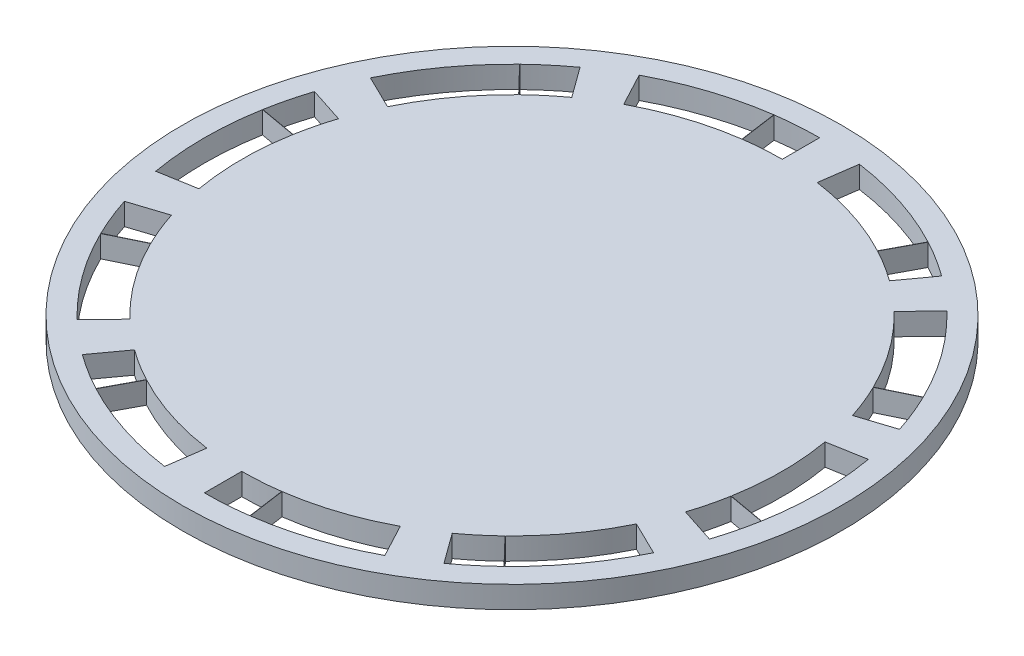
from build123d import *

# Parameters (mm, degrees)
SKETCH1_R           = 38.1
BOSS_EXTRUDE3_DEPTH = 2.54


with BuildPart() as part:
    # Sketch1 → Boss-Extrude3 (new body)
    with BuildSketch(Plane(origin=(0, 0, 0), x_dir=(1, 0, 0), z_dir=(0, 1, 0))):
        with Locations(Location((-25.836673929, 73.693240411, 0), (0, 0, 270))):  # turned: the seam where the file's is
            Circle(SKETCH1_R)
        with BuildLine():
            Line((6.124442357, 89.281718391), (2.243449665, 87.388831779))
            ThreePointArc((2.243449665, 87.388831779), (-0.561364991, 92.056827263), (-4.134157119, 96.166854453))
            Line((-4.134157119, 96.166854453), (-1.134622276, 99.272963711))
            ThreePointArc((-1.134622276, 99.272963711), (2.931970391, 94.594883983), (6.124442357, 89.281718391))
        make_face(mode=Mode.SUBTRACT)
        with BuildLine():
            Line((-4.935030358, 102.461884731), (-7.473087077, 98.968549349))
            ThreePointArc((-7.473087077, 98.968549349), (-9.26937735, 100.180732706), (-11.145376456, 101.265479032))
            Line((-11.145376456, 101.265479032), (-9.114871927, 105.07627624))
            ThreePointArc((-9.114871927, 105.07627624), (-6.979588392, 103.841605625), (-4.935030358, 102.461884731))
        make_face(mode=Mode.SUBTRACT)
        with BuildLine():
            Line((9.183089768, 67.518311213), (4.930689891, 68.268124045))
            ThreePointArc((4.930689891, 68.268124045), (5.405326071, 73.693240411), (4.930689891, 79.118356778))
            Line((4.930689891, 79.118356778), (9.183089768, 79.868169609))
            ThreePointArc((9.183089768, 79.868169609), (9.723326071, 73.693240411), (9.183089768, 67.518311213))
        make_face(mode=Mode.SUBTRACT)
        with BuildLine():
            Line((7.98289579, 84.681884731), (3.876233753, 83.347549349))
            ThreePointArc((3.876233753, 83.347549349), (3.135507895, 85.384059217), (2.25539063, 87.364322037))
            Line((2.25539063, 87.364322037), (6.138033699, 89.253821123))
            ThreePointArc((6.138033699, 89.253821123), (7.139793188, 86.999863442), (7.98289579, 84.681884731))
        make_face(mode=Mode.SUBTRACT)
        with BuildLine():
            Line((-1.134622276, 48.113517111), (-4.134157119, 51.219626369))
            ThreePointArc((-4.134157119, 51.219626369), (-0.561364991, 55.329653559), (2.243449665, 59.997649043))
            Line((2.243449665, 59.997649043), (6.124442357, 58.104762431))
            ThreePointArc((6.124442357, 58.104762431), (2.931970391, 52.79159684), (-1.134622276, 48.113517111))
        make_face(mode=Mode.SUBTRACT)
        with BuildLine():
            Line((7.98289579, 62.704596091), (3.876233753, 64.038931473))
            ThreePointArc((3.876233753, 64.038931473), (4.474004412, 66.1218903), (4.925943869, 68.241276524))
            Line((4.925943869, 68.241276524), (9.177687792, 67.487753059))
            ThreePointArc((9.177687792, 67.487753059), (8.663285158, 65.075443537), (7.98289579, 62.704596091))
        make_face(mode=Mode.SUBTRACT)
        with BuildLine():
            Line((-20.887678459, 38.479307887), (-21.488627909, 42.755285408))
            ThreePointArc((-21.488627909, 42.755285408), (-16.182364991, 43.980332729), (-11.169443364, 46.108191715))
            Line((-11.169443364, 46.108191715), (-9.142265156, 42.295624009))
            ThreePointArc((-9.142265156, 42.295624009), (-14.848029609, 39.873670692), (-20.887678459, 38.479307887))
        make_face(mode=Mode.SUBTRACT)
        with BuildLine():
            Line((-4.935030358, 44.924596091), (-7.473087077, 48.417931473))
            ThreePointArc((-7.473087077, 48.417931473), (-5.765147975, 49.751719785), (-4.153777308, 51.20069591))
            Line((-4.153777308, 51.20069591), (-1.156954198, 48.091970247))
            ThreePointArc((-1.156954198, 48.091970247), (-2.991034632, 46.44272913), (-4.935030358, 44.924596091))
        make_face(mode=Mode.SUBTRACT)
        with BuildLine():
            Line((-42.531082702, 42.295624009), (-40.503904494, 46.108191715))
            ThreePointArc((-40.503904494, 46.108191715), (-35.490982867, 43.980332729), (-30.184719949, 42.755285408))
            Line((-30.184719949, 42.755285408), (-30.785669399, 38.479307887))
            ThreePointArc((-30.785669399, 38.479307887), (-36.825318249, 39.873670692), (-42.531082702, 42.295624009))
        make_face(mode=Mode.SUBTRACT)
        with BuildLine():
            Line((-25.836673929, 38.133240411), (-25.836673929, 42.451240411))
            ThreePointArc((-25.836673929, 42.451240411), (-23.670941071, 42.526396407), (-21.51562802, 42.751502802))
            Line((-21.51562802, 42.751502802), (-20.918410293, 38.475002482))
            ThreePointArc((-20.918410293, 38.475002482), (-23.371612139, 38.218783821), (-25.836673929, 38.133240411))
        make_face(mode=Mode.SUBTRACT)
        with BuildLine():
            Line((-57.797790215, 58.104762431), (-53.916797524, 59.997649043))
            ThreePointArc((-53.916797524, 59.997649043), (-51.111982867, 55.329653559), (-47.539190739, 51.219626369))
            Line((-47.539190739, 51.219626369), (-50.538725583, 48.113517111))
            ThreePointArc((-50.538725583, 48.113517111), (-54.605318249, 52.79159684), (-57.797790215, 58.104762431))
        make_face(mode=Mode.SUBTRACT)
        with BuildLine():
            Line((-46.738317501, 44.924596091), (-44.200260781, 48.417931473))
            ThreePointArc((-44.200260781, 48.417931473), (-42.403970508, 47.205748116), (-40.527971402, 46.12100179))
            Line((-40.527971402, 46.12100179), (-42.558475931, 42.310204583))
            ThreePointArc((-42.558475931, 42.310204583), (-44.693759466, 43.544875197), (-46.738317501, 44.924596091))
        make_face(mode=Mode.SUBTRACT)
        with BuildLine():
            Line((-60.856437626, 79.868169609), (-56.604037749, 79.118356778))
            ThreePointArc((-56.604037749, 79.118356778), (-57.078673929, 73.693240411), (-56.604037749, 68.268124045))
            Line((-56.604037749, 68.268124045), (-60.856437626, 67.518311213))
            ThreePointArc((-60.856437626, 67.518311213), (-61.396673929, 73.693240411), (-60.856437626, 79.868169609))
        make_face(mode=Mode.SUBTRACT)
        with BuildLine():
            Line((-59.656243648, 62.704596091), (-55.549581611, 64.038931473))
            ThreePointArc((-55.549581611, 64.038931473), (-54.808855753, 62.002421606), (-53.928738488, 60.022158786))
            Line((-53.928738488, 60.022158786), (-57.811381557, 58.132659699))
            ThreePointArc((-57.811381557, 58.132659699), (-58.813141046, 60.38661738), (-59.656243648, 62.704596091))
        make_face(mode=Mode.SUBTRACT)
        with BuildLine():
            Line((-50.538725583, 99.272963711), (-47.539190739, 96.166854453))
            ThreePointArc((-47.539190739, 96.166854453), (-51.111982867, 92.056827263), (-53.916797524, 87.388831779))
            Line((-53.916797524, 87.388831779), (-57.797790215, 89.281718391))
            ThreePointArc((-57.797790215, 89.281718391), (-54.605318249, 94.594883983), (-50.538725583, 99.272963711))
        make_face(mode=Mode.SUBTRACT)
        with BuildLine():
            Line((-59.656243648, 84.681884731), (-55.549581611, 83.347549349))
            ThreePointArc((-55.549581611, 83.347549349), (-56.14735227, 81.264590522), (-56.599291727, 79.145204299))
            Line((-56.599291727, 79.145204299), (-60.85103565, 79.898727763))
            ThreePointArc((-60.85103565, 79.898727763), (-60.336633016, 82.311037286), (-59.656243648, 84.681884731))
        make_face(mode=Mode.SUBTRACT)
        with BuildLine():
            Line((-30.785669399, 108.907172936), (-30.184719949, 104.631195415))
            ThreePointArc((-30.184719949, 104.631195415), (-35.490982867, 103.406148093), (-40.503904494, 101.278289107))
            Line((-40.503904494, 101.278289107), (-42.531082702, 105.090856813))
            ThreePointArc((-42.531082702, 105.090856813), (-36.825318249, 107.512810131), (-30.785669399, 108.907172936))
        make_face(mode=Mode.SUBTRACT)
        with BuildLine():
            Line((-46.738317501, 102.461884731), (-44.200260781, 98.968549349))
            ThreePointArc((-44.200260781, 98.968549349), (-45.908199883, 97.634761037), (-47.51957055, 96.185784912))
            Line((-47.51957055, 96.185784912), (-50.51639366, 99.294510575))
            ThreePointArc((-50.51639366, 99.294510575), (-48.682313226, 100.943751693), (-46.738317501, 102.461884731))
        make_face(mode=Mode.SUBTRACT)
        with BuildLine():
            Line((-25.836673929, 109.253240411), (-25.836673929, 104.935240411))
            ThreePointArc((-25.836673929, 104.935240411), (-28.002406787, 104.860084415), (-30.157719838, 104.63497802))
            Line((-30.157719838, 104.63497802), (-30.754937565, 108.91147834))
            ThreePointArc((-30.754937565, 108.91147834), (-28.301735719, 109.167697001), (-25.836673929, 109.253240411))
        make_face(mode=Mode.SUBTRACT)
        with BuildLine():
            Line((-20.887678459, 108.907172936), (-21.488627909, 104.631195415))
            ThreePointArc((-21.488627909, 104.631195415), (-16.182364991, 103.406148093), (-11.169443364, 101.278289107))
            Line((-11.169443364, 101.278289107), (-9.142265156, 105.090856813))
            ThreePointArc((-9.142265156, 105.090856813), (-14.848029609, 107.512810131), (-20.887678459, 108.907172936))
        make_face(mode=Mode.SUBTRACT)
    extrude(amount=BOSS_EXTRUDE3_DEPTH)


solid = part.part
